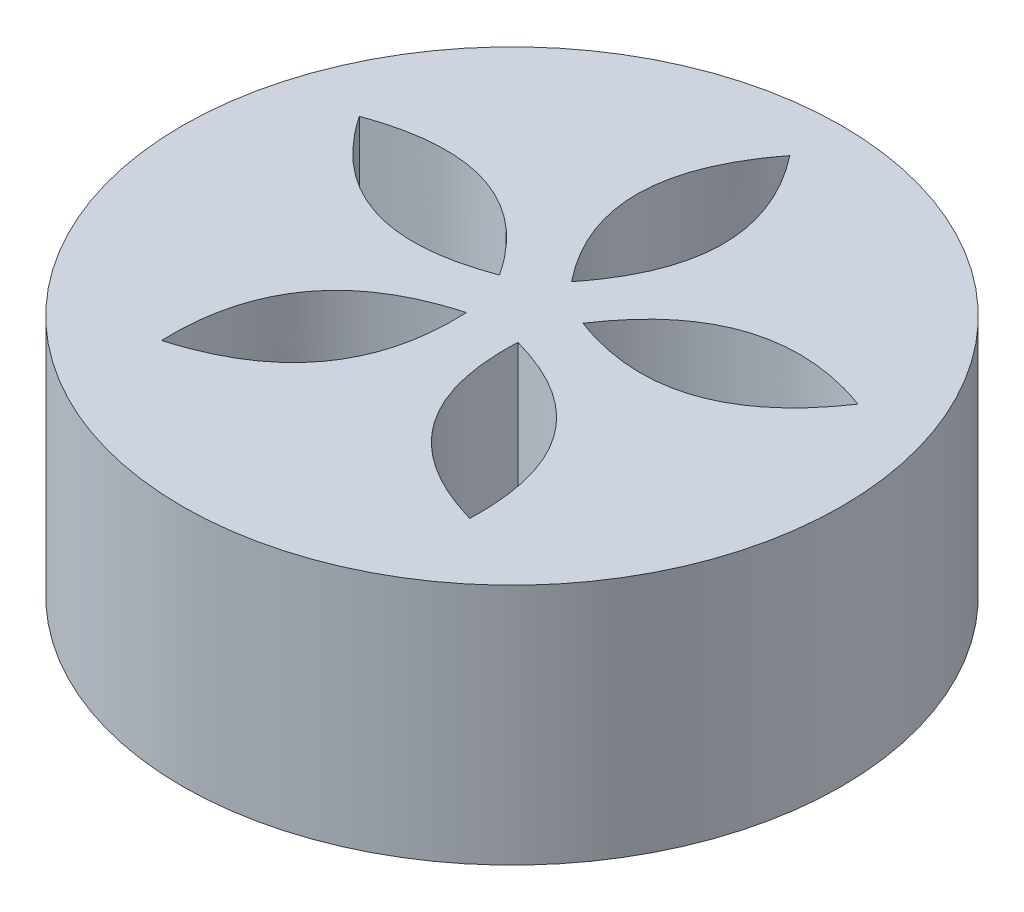
from build123d import *

# Parameters (mm, degrees)
SKETCH_1_R          = 34
EXTRUDE_1_DEPTH     = 25
CUT_EXTRUDE_1_DEPTH = 25


with BuildPart() as part:
    # 草图1 → 凸台-拉伸1 (new body)
    with BuildSketch(Plane(origin=(0, 0, 0), x_dir=(1, 0, 0), z_dir=(0, 1, 0))):
        Circle(SKETCH_1_R)
    extrude(amount=EXTRUDE_1_DEPTH)

    # 草图2 → 切除-拉伸1 (cut)
    with BuildSketch(Plane.XZ):
        with BuildLine():
            add(Edge.make_bspline(
                [(0, -6.142670146), (8.892207312, -17.25267682), (0, -28.653962674)],
                knots=[0, 0, 0, 1, 1, 1], degree=2))
            add(Edge.make_bspline(
                [(0, -6.142670146), (-8.892207312, -17.25267682), (0, -28.653962674)],
                knots=[0, 0, 0, 1, 1, 1], degree=2))
        make_face()
        with BuildLine():
            add(Edge.make_bspline(
                [(-4.304164555, -3.01551155), (-17.618251974, 2.008299288), (-25.713676003, -9.971883506)],
                knots=[0, 0, 0, 1, 1, 1], degree=2))
            add(Edge.make_bspline(
                [(-4.304164555, -3.01551155), (-12.122565621, -14.905684128), (-25.713676003, -9.971883506)],
                knots=[0, 0, 0, 1, 1, 1], degree=2))
        make_face()
        with BuildLine():
            add(Edge.make_bspline(
                [(-2.660119988, 2.044337347), (-1.996471231, 16.259229872), (-15.891925746, 20.256355567)],
                knots=[0, 0, 0, 1, 1, 1], degree=2))
            add(Edge.make_bspline(
                [(-2.660119988, 2.044337347), (-16.384364896, 5.805813236), (-15.891925746, 20.256355567)],
                knots=[0, 0, 0, 1, 1, 1], degree=2))
        make_face()
        with BuildLine():
            add(Edge.make_bspline(
                [(2.660119988, 2.044337347), (16.384364896, 5.805813236), (15.891925746, 20.256355567)],
                knots=[0, 0, 0, 1, 1, 1], degree=2))
            add(Edge.make_bspline(
                [(2.660119988, 2.044337347), (1.996471231, 16.259229872), (15.891925746, 20.256355567)],
                knots=[0, 0, 0, 1, 1, 1], degree=2))
        make_face()
        with BuildLine():
            add(Edge.make_bspline(
                [(4.304164555, -3.01551155), (12.122565621, -14.905684128), (25.713676003, -9.971883506)],
                knots=[0, 0, 0, 1, 1, 1], degree=2))
            add(Edge.make_bspline(
                [(4.304164555, -3.01551155), (17.618251974, 2.008299288), (25.713676003, -9.971883506)],
                knots=[0, 0, 0, 1, 1, 1], degree=2))
        make_face()
    extrude(amount=-CUT_EXTRUDE_1_DEPTH, mode=Mode.SUBTRACT)


solid = part.part
